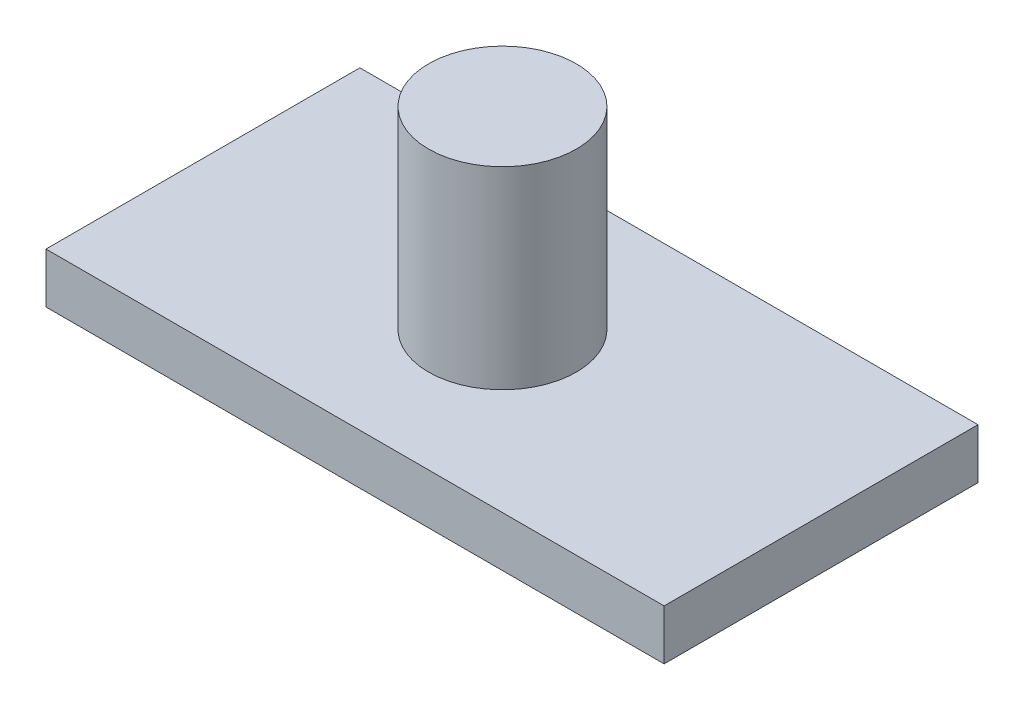
from build123d import *

# Parameters (mm, degrees)
SKETCH1_W           = 81.28
SKETCH1_H           = 41.275
BOSS_EXTRUDE1_DEPTH = 6.604
SKETCH2_R           = 9.71644534
BOSS_EXTRUDE2_DEPTH = 25.4


with BuildPart() as part:
    # Sketch1 → Boss-Extrude1 (new body)
    with BuildSketch(Plane(origin=(0, 0, 0), x_dir=(1, 0, 0), z_dir=(0, 1, 0))):
        with Locations((40.64, -20.6375)):
            Rectangle(SKETCH1_W, SKETCH1_H)
    extrude(amount=BOSS_EXTRUDE1_DEPTH)

    # Sketch2 → Boss-Extrude2 (add)
    with BuildSketch(Plane(origin=(0, 6.604, 0), x_dir=(1, 0, 0), z_dir=(0, 1, 0))):
        with Locations((39.171548595, -20.421551264)):
            Circle(SKETCH2_R)
    extrude(amount=BOSS_EXTRUDE2_DEPTH)


solid = part.part
